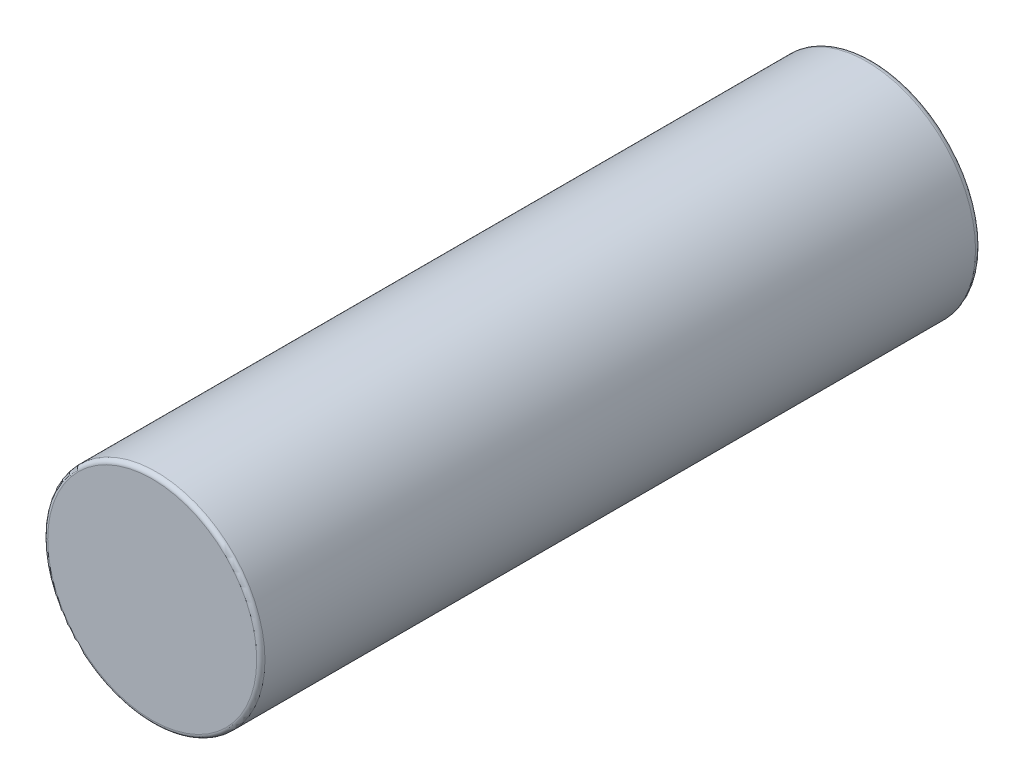
from build123d import *


with BuildPart() as part:
    # Sketch1 → Revolve1 (revolve)
    with BuildSketch(Plane(origin=(0, 0, 0), x_dir=(1, 0, 0), z_dir=(0, 1, 0))):
        with BuildLine():
            Line((0, 70.09), (4.39217757, 70.09))
            ThreePointArc((4.39217757, 70.09), (4.487086316, 70.066046386), (4.559260987, 69.9999233))
            Line((4.559260987, 69.9999233), (5.440739013, 68.6600767))
            ThreePointArc((5.440739013, 68.6600767), (5.512913684, 68.593953614), (5.60782243, 68.57))
            Line((5.60782243, 68.57), (6.955, 68.57))
            Line((6.955, 68.57), (6.955, 68.67))
            Line((6.955, 68.67), (7.745, 68.67))
            Line((7.745, 68.67), (7.745, 68.97))
            Line((7.745, 68.97), (8.1, 68.97))
            Line((8.1, 68.97), (8.1, 69.15596492))
            ThreePointArc((8.1, 69.15596492), (8.127103293, 69.256497147), (8.201067285, 69.32978183))
            ThreePointArc((8.201067285, 69.32978183), (9.040599123, 69.672998391), (9.94, 69.79))
            ThreePointArc((9.94, 69.79), (10.350121933, 69.620121933), (10.52, 69.21))
            Line((10.52, 69.21), (10.52, 0.4))
            ThreePointArc((10.52, 0.4), (10.402842712, 0.117157288), (10.12, 0))
            Line((10.12, 0), (0, 0))
            Line((0, 0), (0, 68.27))
            Line((0, 68.27), (5.338266355, 68.27))
            Line((5.338266355, 68.27), (4.338266355, 69.79))
            Line((4.338266355, 69.79), (0, 69.79))
            Line((0, 69.79), (0, 70.09))
        make_face()
    revolve(axis=Axis((0, 0, 0), (0, 0, -1)))


solid = part.part
